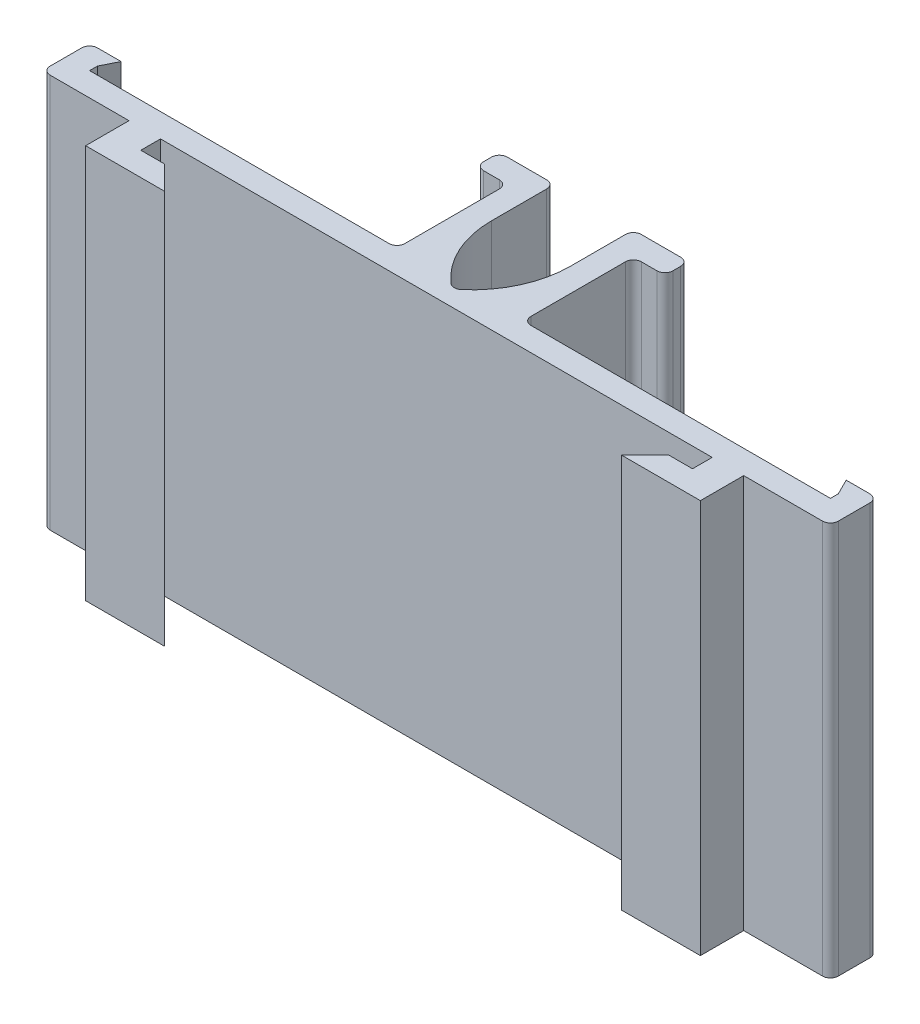
from build123d import *

# Parameters (mm, degrees)
BOSS_EXTRUDE1_DEPTH = 25
FILLET1_R           = 0.5
FILLET2_R           = 0.5
BOSS_EXTRUDE2_DEPTH = 25


with BuildPart() as part:
    # Sketch6 → Boss-Extrude1 (new body)
    with BuildSketch(Plane(origin=(0, 0, 0), x_dir=(1, 0, 0), z_dir=(0, 1, 0))):
        with BuildLine():
            Line((-23.5, 1.5), (-4, 1.5))
            Line((-4, 1.5), (-4, 8.5))
            Line((-4, 8.5), (-6, 8.5))
            Line((-6, 8.5), (-6, 10))
            Line((-6, 10), (-2.5, 10))
            Line((-2.5, 10), (-2.5, 6))
            ThreePointArc((-2.5, 6), (-1.840169944, 3.204915028), (0, 1))
            ThreePointArc((0, 1), (1.840169944, 3.204915028), (2.5, 6))
            Line((2.5, 6), (2.5, 10))
            Line((2.5, 10), (6, 10))
            Line((6, 10), (6, 8.5))
            Line((6, 8.5), (4, 8.5))
            Line((4, 8.5), (4, 1.5))
            Line((4, 1.5), (23.5, 1.5))
            Line((23.5, 1.5), (23.5, 2))
            Line((23.5, 2), (23, 3))
            Line((23, 3), (25, 3))
            Line((25, 3), (25, 0))
            Line((25, 0), (2.5, 0))
            Line((2.5, 0), (-2.5, 0))
            Line((-2.5, 0), (-25, 0))
            Line((-25, 0), (-25, 3))
            Line((-25, 3), (-23, 3))
            Line((-23, 3), (-23.5, 2))
            Line((-23.5, 2), (-23.5, 1.5))
        make_face()
    extrude(amount=BOSS_EXTRUDE1_DEPTH)

    # Fillet1
    fillet1_edges = [part.edges().sort_by_distance(p)[0] for p in [
        (-4, 12.5, -1.5),
        (-4, 12.5, -8.5),
        (0, 12.5, -1),
        (4, 12.5, -8.5),
        (4, 12.5, -1.5),
    ]]
    fillet(fillet1_edges, radius=FILLET1_R)

    # Fillet2
    fillet2_edges = [part.edges().sort_by_distance(p)[0] for p in [
        (-6, 12.5, -8.5),
        (-6, 12.5, -10),
        (-2.5, 12.5, -10),
        (2.5, 12.5, -10),
        (6, 12.5, -10),
        (6, 12.5, -8.5),
        (25, 12.5, -3),
        (25, 12.5, 0),
        (-25, 12.5, 0),
        (-25, 12.5, -3),
    ]]
    fillet(fillet2_edges, radius=FILLET2_R)

    # Sketch7 → Boss-Extrude2 (add)
    with BuildSketch(Plane(origin=(0, 25, 0), x_dir=(1, 0, 0), z_dir=(0, 1, 0))):
        Polygon((-19.5, 0), (-19.5, -2.75), (-14.5, -2.75), (-16, -1.25), (-17.5, -1.25), (-17.5, 0), align=None)
        Polygon((19.5, 0), (17.5, 0), (17.5, -1.25), (16, -1.25), (14.5, -2.75), (19.5, -2.75), align=None)
    extrude(amount=-BOSS_EXTRUDE2_DEPTH)


solid = part.part
